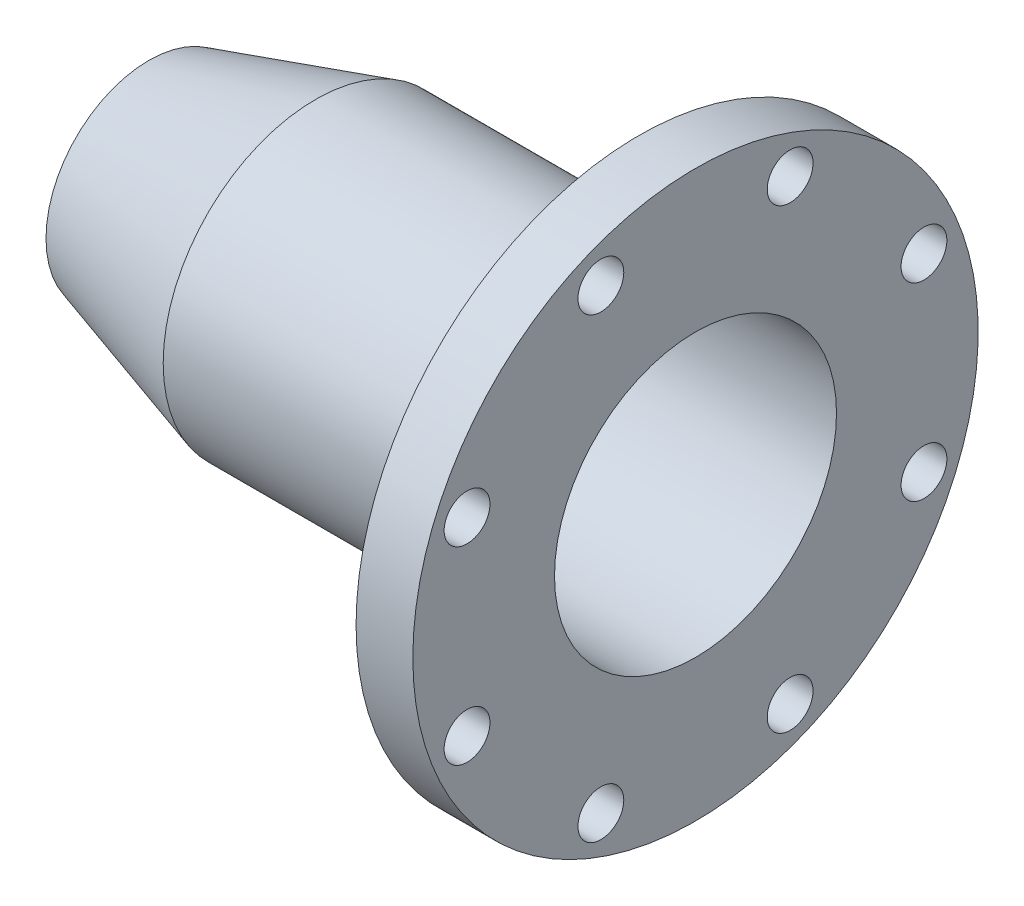
from build123d import *

# Parameters (mm, degrees)
SKETCH1_W                   = 27.69
SKETCH1_H                   = 63.625
F_7_8_0_88_DIAMETER_HOLE1_D = 22.352
CIRPATTERN1_COUNT           = 8


with BuildPart() as part:
    # Sketch1 → Revolve1 (revolve)
    with BuildSketch(Plane.XY):
        Polygon((239.01, 68.795), (266.7, 68.795), (266.7, 74.295), (239.01, 74.295), (81.28, 74.295), (0, 50.18683312), (0, 44.45), (82.078476138, 68.795), align=None)
        with Locations((252.855, 106.1075)):
            Rectangle(SKETCH1_W, SKETCH1_H)
    revolve(axis=Axis((0, 0, 0), (1, 0, 0)))

    # 7/8 (0.88) Diameter Hole1 (through all)
    with Locations(Plane(origin=(266.7, 111.466065597, 46.170756115), x_dir=(0, 0, 1), z_dir=(1, 0, 0))):
        with Locations((0, 0)):
            f_7_8_0_88_diameter_hole1 = Hole(F_7_8_0_88_DIAMETER_HOLE1_D / 2)

    # CirPattern1: 7/8 (0.88) Diameter Hole1 ×8 about axis
    cirpattern1_axis = Axis((0, 0, 0), (1, 0, 0))
    for i in range(1, CIRPATTERN1_COUNT):
        add(f_7_8_0_88_diameter_hole1.rotate(cirpattern1_axis, i * 360 / CIRPATTERN1_COUNT), mode=Mode.SUBTRACT)


solid = part.part
